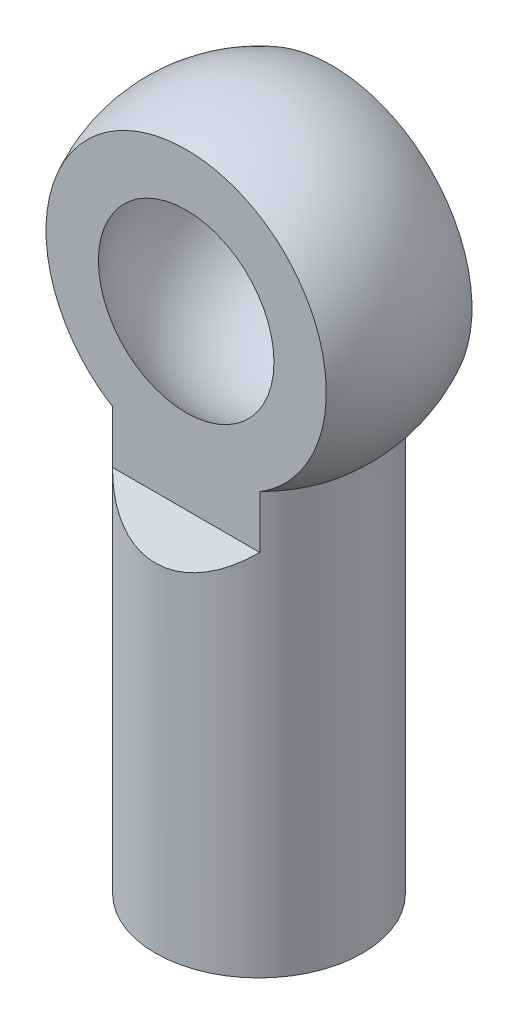
from build123d import *

# Parameters (mm, degrees)
SKETCH1_R               = 2.95
BOSS_EXTRUDE1_DEPTH     = 12
SKETCH5_R               = 1.5
CUT_EXTRUDE3_DEPTH      = 11
CUT_EXTRUDE4_DEPTH      = 5.5
CUT_EXTRUDE4_DEPTH_BACK = 5.5
SKETCH12_R              = 3.400000058
SKETCH12_R_2            = 2.501374622
BOSS_EXTRUDE5_DEPTH     = 0.02


with BuildPart() as part:
    # Sketch1 → Boss-Extrude1 (new body)
    with BuildSketch(Plane(origin=(0, 0, 0), x_dir=(1, 0, 0), z_dir=(0, 1, 0))):
        Circle(SKETCH1_R)
    extrude(amount=BOSS_EXTRUDE1_DEPTH)

    # Sketch5 → Cut-Extrude3 (cut)
    with BuildSketch(Plane.XZ):
        Circle(SKETCH5_R)
    extrude(amount=-CUT_EXTRUDE3_DEPTH, mode=Mode.SUBTRACT)

    # Sketch2 → Revolve3 (revolve)
    with BuildSketch(Plane(origin=(0, 0, 0), x_dir=(0, 0, -1), z_dir=(1, 0, 0))):
        with BuildLine():
            Line((0, 19.898161268), (0, 10.898161268))
            ThreePointArc((0, 10.898161268), (4.5, 15.398161268), (0, 19.898161268))
        make_face()
    revolve(axis=Axis((0, 12, 0), (0, -1, 0)))

    # Sketch8 → Cut-Extrude4 (cut, two sides)
    with BuildSketch(Plane(origin=(0, 0, 0), x_dir=(0, 0, -1), z_dir=(1, 0, 0))) as cut_extrude4_sk:
        Polygon((-2.075, 20.390789919), (-2.075, 10.5), (-5.08, 7.495), (-5.08, 20.390789919), align=None)
        Polygon((5.08, 20.390789919), (2.075, 20.390789919), (2.075, 10.5), (5.08, 7.495), align=None)
    extrude(amount=CUT_EXTRUDE4_DEPTH, mode=Mode.SUBTRACT)
    extrude(cut_extrude4_sk.sketch, amount=-CUT_EXTRUDE4_DEPTH_BACK, mode=Mode.SUBTRACT)

    # Sketch11 → Cut-Revolve2 (revolve, cut)
    with BuildSketch(Plane(origin=(0, 0, 0), x_dir=(0, 0, -1), z_dir=(1, 0, 0))):
        with BuildLine():
            Line((-3.25, 15.398161268), (3.25, 15.398161268))
            ThreePointArc((3.25, 15.398161268), (0, 18.648161268), (-3.25, 15.398161268))
        make_face()
    revolve(axis=Axis((0, 15.398161268, 2.075), (0, 0, -1)), mode=Mode.SUBTRACT)

    # Sketch12 → Boss-Extrude5 (add)
    with BuildSketch(Plane(origin=(0, 0, -2.075), x_dir=(-1, 0, 0), z_dir=(0, 0, -1))):
        with Locations((0, 15.398161268)):
            Circle(SKETCH12_R)
        with Locations((0, 15.398161268)):
            Circle(SKETCH12_R_2, mode=Mode.SUBTRACT)
    extrude(amount=BOSS_EXTRUDE5_DEPTH)


solid = part.part
